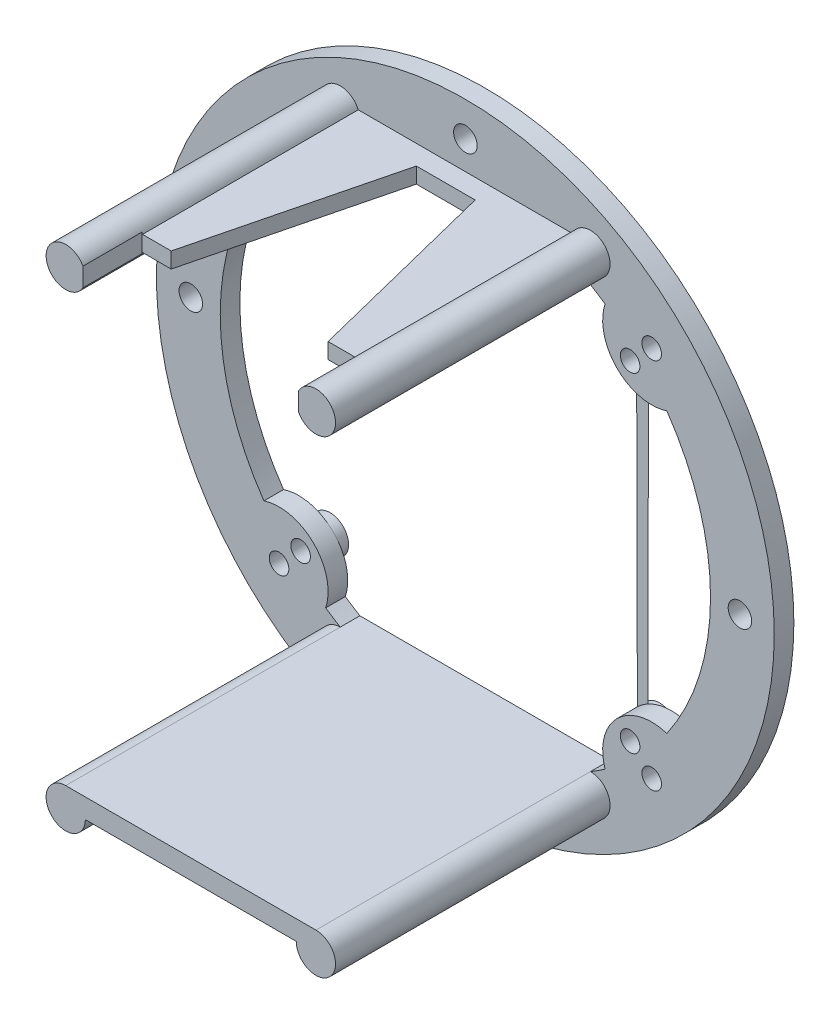
from build123d import *

# Parameters (mm, degrees)
SKETCH1_R           = 31.5
BOSS_EXTRUDE1_DEPTH = 2
SKETCH2_R           = 1
SKETCH2_R_2         = 1.2
CUT_EXTRUDE2_DEPTH  = 3
SKETCH5_R           = 1
BOSS_EXTRUDE3_DEPTH = 1
BOSS_EXTRUDE2_DEPTH = 30
CUT_EXTRUDE3_DEPTH  = 32.5


with BuildPart() as part:
    # Sketch1 → Boss-Extrude1 (new body)
    with BuildSketch(Plane.XY):
        Circle(SKETCH1_R)
        with BuildLine():
            Line((-12.757350822, -21.5), (12.757350822, -21.5))
            ThreePointArc((12.757350822, -21.5), (13.509438116, -21.035567066), (14.244636813, -20.544836871))
            ThreePointArc((14.244636813, -20.544836871), (15.464466094, -15.464466094), (20.544836871, -14.244636813))
            ThreePointArc((20.544836871, -14.244636813), (25, 0), (20.544836871, 14.244636813))
            ThreePointArc((20.544836871, 14.244636813), (15.464466094, 15.464466094), (14.244636813, 20.544836871))
            ThreePointArc((14.244636813, 20.544836871), (11.482464544, 22.207048611), (8.529361055, 23.5))
            Line((8.529361055, 23.5), (-8.529361055, 23.5))
            ThreePointArc((-8.529361055, 23.5), (-11.482464544, 22.207048611), (-14.244636813, 20.544836871))
            ThreePointArc((-14.244636813, 20.544836871), (-15.464466094, 15.464466094), (-20.544836871, 14.244636813))
            ThreePointArc((-20.544836871, 14.244636813), (-25, 0), (-20.544836871, -14.244636813))
            ThreePointArc((-20.544836871, -14.244636813), (-15.464466094, -15.464466094), (-14.244636813, -20.544836871))
            ThreePointArc((-14.244636813, -20.544836871), (-13.509438116, -21.035567066), (-12.757350822, -21.5))
        make_face(mode=Mode.SUBTRACT)
    extrude(amount=BOSS_EXTRUDE1_DEPTH)

    # Sketch2 → Cut-Extrude2 (cut, through all)
    with BuildSketch(Plane.XY):
        with Locations((-19, 19)):
            Circle(SKETCH2_R)
        with Locations((-16.8, 16.8)):
            Circle(SKETCH2_R)
        with Locations((19, 19)):
            Circle(SKETCH2_R)
        with Locations((16.8, 16.8)):
            Circle(SKETCH2_R)
        with Locations((-19, -19)):
            Circle(SKETCH2_R)
        with Locations((-16.8, -16.8)):
            Circle(SKETCH2_R)
        with Locations((19, -19)):
            Circle(SKETCH2_R)
        with Locations((16.8, -16.8)):
            Circle(SKETCH2_R)
        with Locations((-28, 0)):
            Circle(SKETCH2_R_2)
        with Locations((28, 0)):
            Circle(SKETCH2_R_2)
        with Locations((0, 28)):
            Circle(SKETCH2_R_2)
        with Locations((0, -28)):
            Circle(SKETCH2_R_2)
    extrude(amount=CUT_EXTRUDE2_DEPTH, mode=Mode.SUBTRACT)

    # Sketch5 → Boss-Extrude3 (add)
    with BuildSketch(Plane(origin=(0, 0, 0), x_dir=(-1, 0, 0), z_dir=(0, 0, -1))):
        with BuildLine():
            Line((-17.664466094, 20.335533906), (-15.464466094, 18.135533906))
            ThreePointArc((-15.464466094, 18.135533906), (-15.464466094, 15.464466094), (-18.135533906, 15.464466094))
            Line((-18.135533906, 15.464466094), (-20.335533906, 17.664466094))
            ThreePointArc((-20.335533906, 17.664466094), (-20.335533906, 20.335533906), (-17.664466094, 20.335533906))
        make_face()
        with Locations((-19, 19)):
            Circle(SKETCH5_R, mode=Mode.SUBTRACT)
        with Locations((-16.8, 16.8)):
            Circle(SKETCH5_R, mode=Mode.SUBTRACT)
        with BuildLine():
            Line((20.335533906, 17.664466094), (18.135533906, 15.464466094))
            ThreePointArc((18.135533906, 15.464466094), (15.464466094, 15.464466094), (15.464466094, 18.135533906))
            Line((15.464466094, 18.135533906), (17.664466094, 20.335533906))
            ThreePointArc((17.664466094, 20.335533906), (20.335533906, 20.335533906), (20.335533906, 17.664466094))
        make_face()
        with Locations((16.8, 16.8)):
            Circle(SKETCH5_R, mode=Mode.SUBTRACT)
        with Locations((19, 19)):
            Circle(SKETCH5_R, mode=Mode.SUBTRACT)
        with BuildLine():
            Line((17.664466094, -20.335533906), (15.464466094, -18.135533906))
            ThreePointArc((15.464466094, -18.135533906), (15.464466094, -15.464466094), (18.135533906, -15.464466094))
            Line((18.135533906, -15.464466094), (20.335533906, -17.664466094))
            ThreePointArc((20.335533906, -17.664466094), (20.335533906, -20.335533906), (17.664466094, -20.335533906))
        make_face()
        with Locations((16.8, -16.8)):
            Circle(SKETCH5_R, mode=Mode.SUBTRACT)
        with Locations((19, -19)):
            Circle(SKETCH5_R, mode=Mode.SUBTRACT)
        with BuildLine():
            Line((-20.335533906, -17.664466094), (-18.135533906, -15.464466094))
            ThreePointArc((-18.135533906, -15.464466094), (-15.464466094, -15.464466094), (-15.464466094, -18.135533906))
            Line((-15.464466094, -18.135533906), (-17.664466094, -20.335533906))
            ThreePointArc((-17.664466094, -20.335533906), (-20.335533906, -20.335533906), (-20.335533906, -17.664466094))
        make_face()
        with Locations((-16.8, -16.8)):
            Circle(SKETCH5_R, mode=Mode.SUBTRACT)
        with Locations((-19, -19)):
            Circle(SKETCH5_R, mode=Mode.SUBTRACT)
    extrude(amount=BOSS_EXTRUDE3_DEPTH)

    # Sketch3 → Boss-Extrude2 (add)
    with BuildSketch(Plane.XY):
        with BuildLine():
            Line((-10.924320544, 23.5), (10.924320544, 23.5))
            ThreePointArc((10.924320544, 23.5), (14.757350822, 24.3), (10.924320544, 25.1))
            Line((10.924320544, 25.1), (-10.924320544, 25.1))
            ThreePointArc((-10.924320544, 25.1), (-14.757350822, 24.3), (-10.924320544, 23.5))
        make_face()
        with BuildLine():
            Line((-12.757350822, -21.5), (12.757350822, -21.5))
            ThreePointArc((12.757350822, -21.5), (14.171564385, -24.914213562), (10.757350822, -23.5))
            Line((10.757350822, -23.5), (-10.757350822, -23.5))
            ThreePointArc((-10.757350822, -23.5), (-14.171564385, -24.914213562), (-12.757350822, -21.5))
        make_face()
    extrude(amount=BOSS_EXTRUDE2_DEPTH)

    # Sketch4 → Cut-Extrude3 (cut, through all)
    with BuildSketch(Plane(origin=(0, 0, 0), x_dir=(1, 0, 0), z_dir=(0, 1, 0))):
        Polygon((-11, -30), (-11, -24), (-8, -24), (-3, -4), (3, -4), (8, -24), (11, -24), (11, -30), align=None)
    extrude(amount=CUT_EXTRUDE3_DEPTH, mode=Mode.SUBTRACT)


solid = part.part
